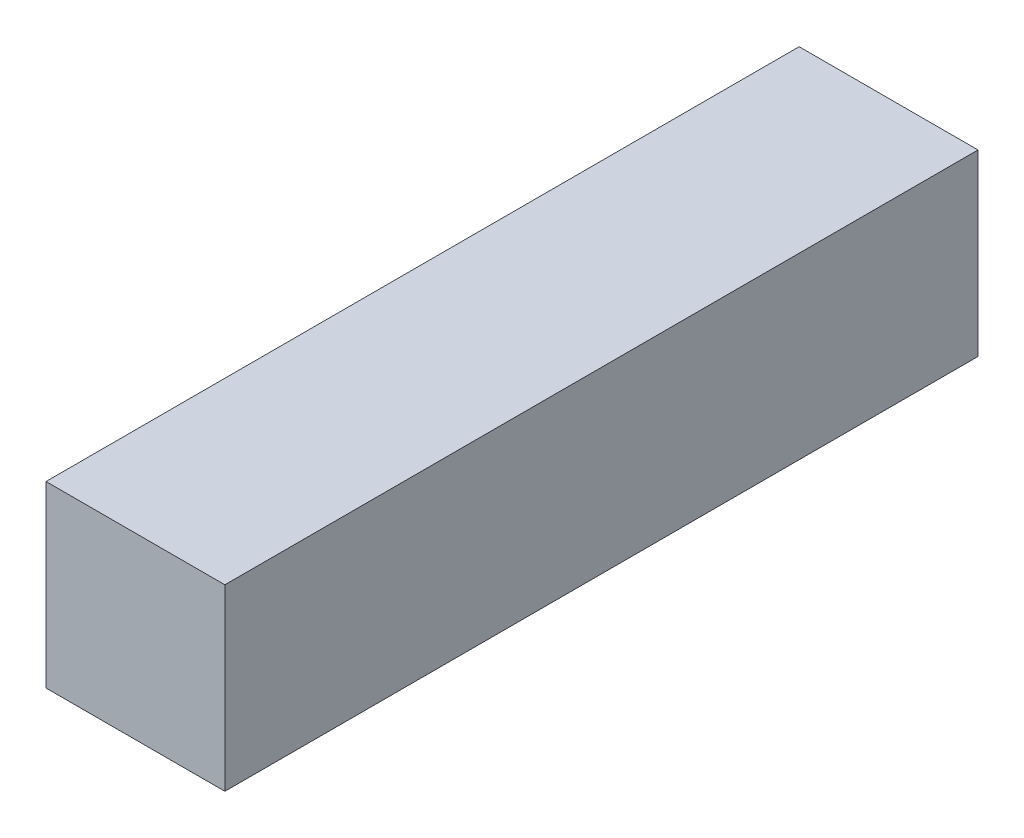
from build123d import *

# Parameters (mm, degrees)
SKETCH1_W           = 19
SKETCH1_H           = 19
BOSS_EXTRUDE1_DEPTH = 80


with BuildPart() as part:
    # Sketch1 → Boss-Extrude1 (new body)
    with BuildSketch(Plane.XY):
        Rectangle(SKETCH1_W, SKETCH1_H)
    extrude(amount=BOSS_EXTRUDE1_DEPTH)


solid = part.part
